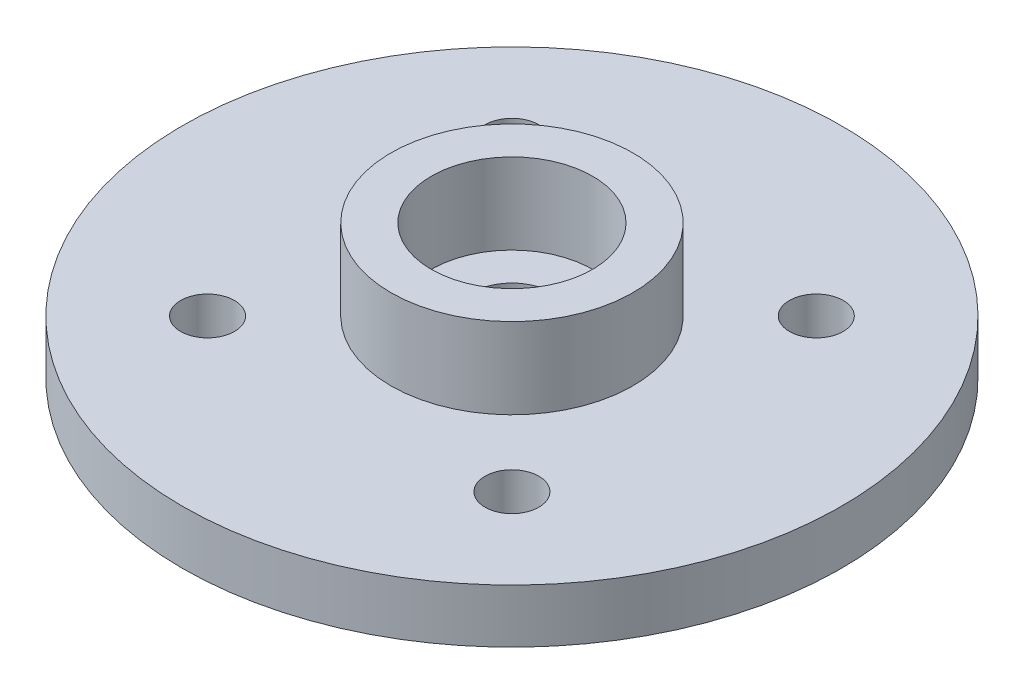
from build123d import *

# Parameters (mm, degrees)
SKETCH1_R           = 12.25
SKETCH1_R_2         = 1
SKETCH1_R_3         = 1.5
BOSS_EXTRUDE1_DEPTH = 2
SKETCH2_R           = 4.5
SKETCH2_R_2         = 3
BOSS_EXTRUDE2_DEPTH = 3


with BuildPart() as part:
    # Sketch1 → Boss-Extrude1 (new body)
    with BuildSketch(Plane(origin=(0, 0, 0), x_dir=(1, 0, 0), z_dir=(0, 1, 0))):
        Circle(SKETCH1_R)
        with Locations((-5.656854249, 5.656854249)):
            Circle(SKETCH1_R_2, mode=Mode.SUBTRACT)
        with Locations((5.656854249, 5.656854249)):
            Circle(SKETCH1_R_2, mode=Mode.SUBTRACT)
        with Locations((-5.656854249, -5.656854249)):
            Circle(SKETCH1_R_2, mode=Mode.SUBTRACT)
        with Locations((5.656854249, -5.656854249)):
            Circle(SKETCH1_R_2, mode=Mode.SUBTRACT)
        Circle(SKETCH1_R_3, mode=Mode.SUBTRACT)
    extrude(amount=BOSS_EXTRUDE1_DEPTH)

    # Sketch2 → Boss-Extrude2 (add)
    with BuildSketch(Plane(origin=(0, 2, 0), x_dir=(1, 0, 0), z_dir=(0, 1, 0))):
        Circle(SKETCH2_R)
        Circle(SKETCH2_R_2, mode=Mode.SUBTRACT)
    extrude(amount=BOSS_EXTRUDE2_DEPTH)


solid = part.part
